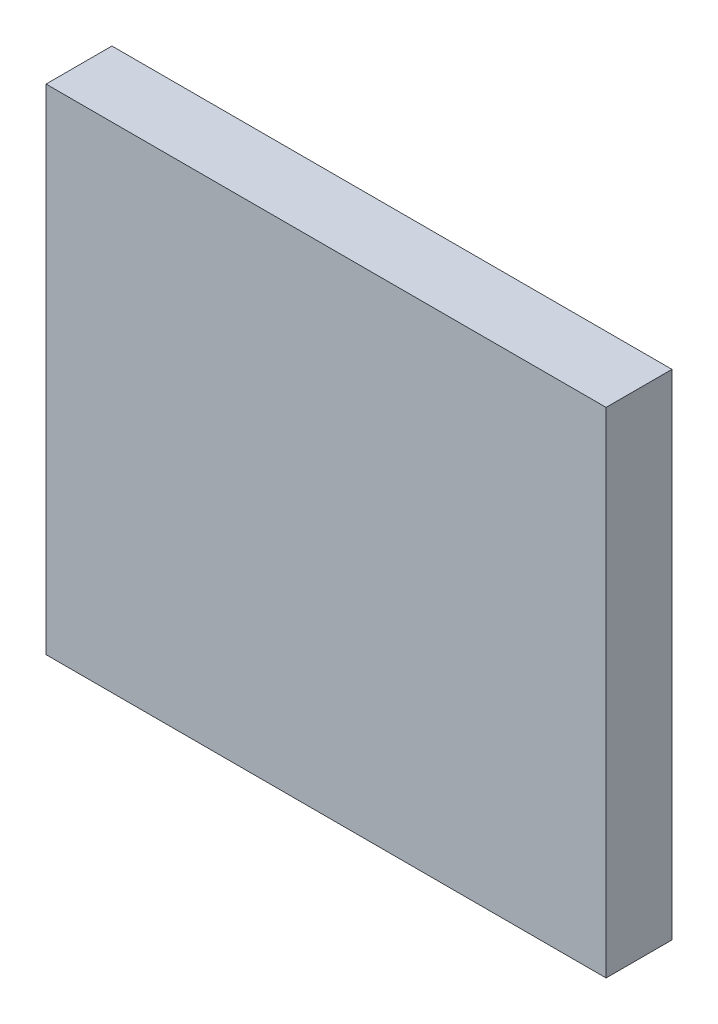
from build123d import *

# Parameters (mm, degrees)
SKETCH1_W           = 17
SKETCH1_H           = 2
BOSS_EXTRUDE1_DEPTH = 15


with BuildPart() as part:
    # Sketch1 → Boss-Extrude1 (new body)
    with BuildSketch(Plane(origin=(0, 0, 0), x_dir=(1, 0, 0), z_dir=(0, 1, 0))):
        with Locations((8.5, 1)):
            Rectangle(SKETCH1_W, SKETCH1_H)
    extrude(amount=BOSS_EXTRUDE1_DEPTH)


solid = part.part
